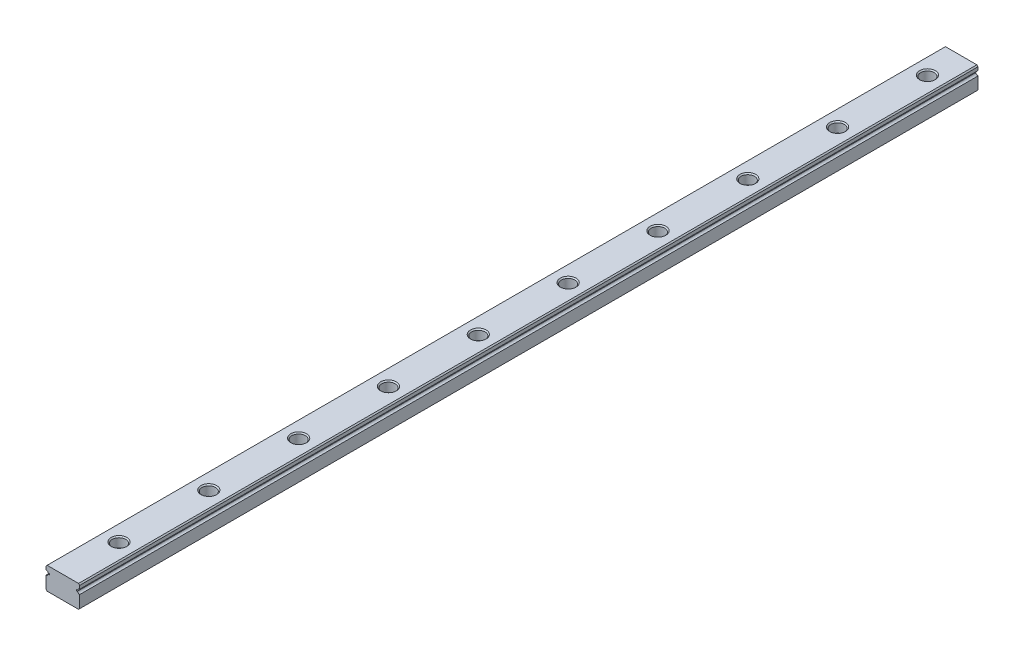
from build123d import *

# Parameters (mm, degrees)
BOSS_EXTRUDE1_DEPTH = 400
CHAMFER1_SIZE       = 0.5
LPATTERN1_COUNT     = 10
LPATTERN1_PITCH     = 40


with BuildPart() as part:
    # Sketch1 → Boss-Extrude1 (new body)
    with BuildSketch(Plane.XY):
        with BuildLine():
            Line((-7.5, 10), (7.5, 10))
            Line((7.5, 10), (7.5, 8.25))
            Line((7.5, 8.25), (7.5, 8.030776406))
            ThreePointArc((7.5, 8.030776406), (6.865647614, 7.812463569), (6.5, 7.25))
            Line((6.5, 7.25), (6, 7.25))
            Line((6, 7.25), (6, 6.75))
            Line((6, 6.75), (6.5, 6.75))
            ThreePointArc((6.5, 6.75), (6.865647614, 6.187536431), (7.5, 5.969223594))
            Line((7.5, 5.969223594), (7.5, 5.75))
            Line((7.5, 5.75), (7.5, 0))
            Line((7.5, 0), (-7.5, 0))
            Line((-7.5, 0), (-7.5, 5.75))
            Line((-7.5, 5.75), (-7.5, 5.969223594))
            ThreePointArc((-7.5, 5.969223594), (-6.865647614, 6.187536431), (-6.5, 6.75))
            Line((-6.5, 6.75), (-6, 6.75))
            Line((-6, 6.75), (-6, 7.25))
            Line((-6, 7.25), (-6.5, 7.25))
            ThreePointArc((-6.5, 7.25), (-6.865647614, 7.812463569), (-7.5, 8.030776406))
            Line((-7.5, 8.030776406), (-7.5, 8.25))
            Line((-7.5, 8.25), (-7.5, 10))
        make_face()
    extrude(amount=BOSS_EXTRUDE1_DEPTH)

    # Chamfer1
    chamfer1_edges = [part.edges().sort_by_distance(p)[0] for p in [
        (-7.5, 10, 200),
        (7.5, 10, 200),
        (7.5, 0, 200),
        (-7.5, 0, 200),
    ]]
    chamfer(chamfer1_edges, length=CHAMFER1_SIZE)

    # Sketch3 → M3 六角承窩頭蓋螺釘的柱孔1 (revolve, cut)
    with BuildSketch(Plane(origin=(0, 10, 15), x_dir=(0, 0, 1), z_dir=(1, 0, 0))):
        Polygon((0, 0), (0, 10), (2, 10), (1.75, 9.75), (1.75, 4.5), (3, 4.5), (3, 0.5), (3.5, 0), align=None)
    hole_wizard_m3_1 = revolve(axis=Axis((0, 16.35, 15), (0, -1, 0)), mode=Mode.SUBTRACT)

    # LPattern1: M3 六角承窩頭蓋螺釘的柱孔1 ×10
    with Locations(*[(0, 0, i * LPATTERN1_PITCH) for i in range(1, LPATTERN1_COUNT)]):
        add(hole_wizard_m3_1, mode=Mode.SUBTRACT)


solid = part.part
